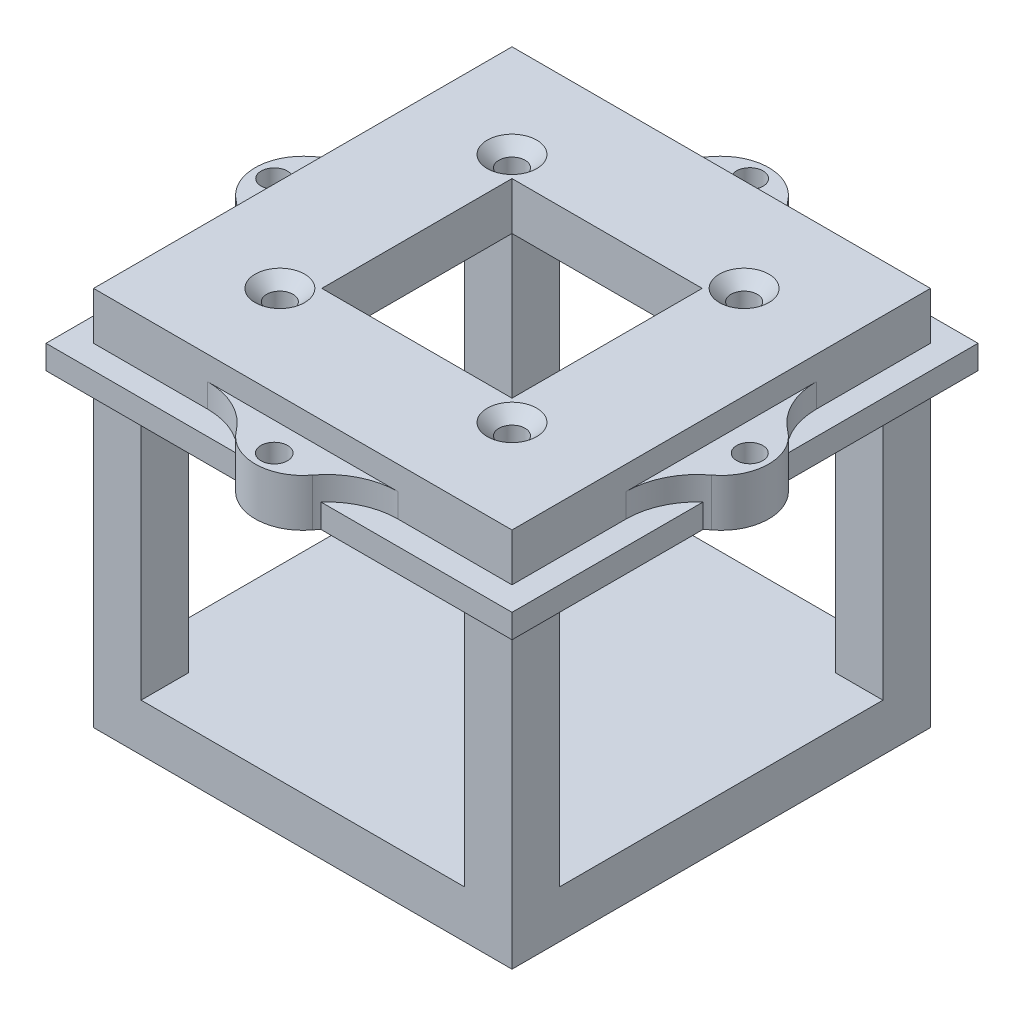
from build123d import *

# Parameters (mm, degrees)
SKETCH1_W                = 55.88
SKETCH1_H                = 55.88
BOSS_EXTRUDE1_DEPTH      = 50.8
SKETCH2_W                = 43.18
SKETCH2_H                = 38.1
CUT_EXTRUDE1_DEPTH       = 56.88
SKETCH3_W                = 43.18
SKETCH3_H                = 38.1
CUT_EXTRUDE2_DEPTH       = 56.88
SKETCH4_R                = 1.75
SKETCH4_W                = 25.4
SKETCH4_H                = 25.4
CUT_EXTRUDE3_DEPTH       = 44.45
BOSS_EXTRUDE2_DEPTH      = 3.175
BOSS_EXTRUDE2_DEPTH_BACK = 3.175
SKETCH10_W               = 9.525
SKETCH10_H               = 3.175
BOSS_EXTRUDE5_DEPTH      = 55.88
SKETCH12_W               = 62.23
SKETCH12_H               = 3.175
BOSS_EXTRUDE6_DEPTH      = 3.175
BOSS_EXTRUDE6_DEPTH_BACK = 6.35
SKETCH13_W               = 62.23
SKETCH13_H               = 3.175
BOSS_EXTRUDE7_DEPTH      = 3.175
BOSS_EXTRUDE7_DEPTH_BACK = 6.35
SKETCH11_R               = 1.75
SKETCH11_R_2             = 1.778
CUT_EXTRUDE4_DEPTH       = 48.625
SKETCH15_R               = 2.54
SKETCH15_R_2             = 1.75
SKETCH15_R_3             = 1.778
BOSS_EXTRUDE8_DEPTH      = 7.239
SKETCH16_R               = 1.651
BOSS_EXTRUDE9_DEPTH      = 3.175


with BuildPart() as part:
    # Sketch1 → Boss-Extrude1 (new body)
    with BuildSketch(Plane(origin=(0, 0, 0), x_dir=(1, 0, 0), z_dir=(0, 1, 0))):
        with Locations((27.94, 27.94)):
            Rectangle(SKETCH1_W, SKETCH1_H)
    extrude(amount=BOSS_EXTRUDE1_DEPTH)

    # Sketch2 → Cut-Extrude1 (cut, through all)
    with BuildSketch(Plane.XY):
        with Locations((27.94, 25.4)):
            Rectangle(SKETCH2_W, SKETCH2_H)
    extrude(amount=-CUT_EXTRUDE1_DEPTH, mode=Mode.SUBTRACT)

    # Sketch3 → Cut-Extrude2 (cut, through all)
    with BuildSketch(Plane(origin=(55.88, 0, 0), x_dir=(0, 0, -1), z_dir=(1, 0, 0))):
        with Locations((27.94, 25.4)):
            Rectangle(SKETCH3_W, SKETCH3_H)
    extrude(amount=-CUT_EXTRUDE2_DEPTH, mode=Mode.SUBTRACT)

    # Sketch4 → Cut-Extrude3 (cut)
    with BuildSketch(Plane(origin=(0, 50.8, 0), x_dir=(1, 0, 0), z_dir=(0, 1, 0))):
        with Locations((43.44, 43.44)):
            Circle(SKETCH4_R)
        with Locations((43.44, 12.44)):
            Circle(SKETCH4_R)
        with Locations((12.44, 12.44)):
            Circle(SKETCH4_R)
        with Locations((12.44, 43.44)):
            Circle(SKETCH4_R)
        with Locations((27.94, 27.94)):
            Rectangle(SKETCH4_W, SKETCH4_H)
    extrude(amount=-CUT_EXTRUDE3_DEPTH, mode=Mode.SUBTRACT)

    # Sketch5 → Cut-Revolve1 (revolve, cut)
    with BuildSketch(Plane(origin=(12.44, 0, 0), x_dir=(0, 0, -1), z_dir=(1, 0, 0))):
        Polygon((43.44, 50.8), (40.138, 50.8), (43.44, 47.498), align=None)
    revolve(axis=Axis((12.44, 47.498, -43.44), (0, 1, 0)), mode=Mode.SUBTRACT)

    # Sketch6 → Cut-Revolve2 (revolve, cut)
    with BuildSketch(Plane(origin=(12.44, 0, 0), x_dir=(0, 0, -1), z_dir=(1, 0, 0))):
        Polygon((12.44, 50.8), (9.138, 50.8), (12.44, 47.498), align=None)
    revolve(axis=Axis((12.44, 47.498, -12.44), (0, 1, 0)), mode=Mode.SUBTRACT)

    # Sketch7 → Cut-Revolve3 (revolve, cut)
    with BuildSketch(Plane(origin=(43.44, 0, 0), x_dir=(0, 0, -1), z_dir=(1, 0, 0))):
        Polygon((43.44, 50.8), (40.138, 50.8), (43.44, 47.498), align=None)
    revolve(axis=Axis((43.44, 47.498, -43.44), (0, 1, 0)), mode=Mode.SUBTRACT)

    # Sketch8 → Cut-Revolve4 (revolve, cut)
    with BuildSketch(Plane(origin=(43.44, 0, 0), x_dir=(0, 0, -1), z_dir=(1, 0, 0))):
        Polygon((12.44, 50.8), (9.138, 50.8), (12.44, 47.498), align=None)
    revolve(axis=Axis((43.44, 47.498, -12.44), (0, 1, 0)), mode=Mode.SUBTRACT)

    # Sketch9 → Boss-Extrude2 (add, two sides)
    with BuildSketch(Plane.XZ.offset(-44.45)) as boss_extrude2_sk:
        with BuildLine():
            Line((0, -40.64), (0, -15.24))
            ThreePointArc((0, -15.24), (-1.005581006, -19.499709497), (-3.81, -22.86))
            ThreePointArc((-3.81, -22.86), (-6.35, -27.94), (-3.81, -33.02))
            ThreePointArc((-3.81, -33.02), (-1.005581006, -36.380290503), (0, -40.64))
        make_face()
        with BuildLine():
            Line((55.88, -40.64), (55.88, -15.24))
            ThreePointArc((55.88, -15.24), (56.885581006, -19.499709497), (59.69, -22.86))
            ThreePointArc((59.69, -22.86), (62.23, -27.94), (59.69, -33.02))
            ThreePointArc((59.69, -33.02), (56.885581006, -36.380290503), (55.88, -40.64))
        make_face()
        with BuildLine():
            Line((15.24, 0), (40.64, 0))
            ThreePointArc((40.64, 0), (36.380290503, 1.005581006), (33.02, 3.81))
            ThreePointArc((33.02, 3.81), (27.94, 6.35), (22.86, 3.81))
            ThreePointArc((22.86, 3.81), (19.499709497, 1.005581006), (15.24, 0))
        make_face()
        with BuildLine():
            Line((15.24, -55.88), (40.64, -55.88))
            ThreePointArc((40.64, -55.88), (36.380290503, -56.885581006), (33.02, -59.69))
            ThreePointArc((33.02, -59.69), (27.94, -62.23), (22.86, -59.69))
            ThreePointArc((22.86, -59.69), (19.499709497, -56.885581006), (15.24, -55.88))
        make_face()
    extrude(amount=BOSS_EXTRUDE2_DEPTH)
    extrude(boss_extrude2_sk.sketch, amount=-BOSS_EXTRUDE2_DEPTH_BACK)

    # Sketch10 → Boss-Extrude5 (add)
    with BuildSketch(Plane.XY):
        with Locations((54.2925, 42.8625)):
            Rectangle(SKETCH10_W, SKETCH10_H)
        with Locations((1.5875, 42.8625)):
            Rectangle(SKETCH10_W, SKETCH10_H)
    extrude(amount=-BOSS_EXTRUDE5_DEPTH)

    # Sketch12 → Boss-Extrude6 (add, two sides)
    with BuildSketch(Plane(origin=(0, 0, -55.88), x_dir=(-1, 0, 0), z_dir=(0, 0, -1))) as boss_extrude6_sk:
        with Locations((-27.94, 42.8625)):
            Rectangle(SKETCH12_W, SKETCH12_H)
    extrude(amount=BOSS_EXTRUDE6_DEPTH)
    extrude(boss_extrude6_sk.sketch, amount=-BOSS_EXTRUDE6_DEPTH_BACK)

    # Sketch13 → Boss-Extrude7 (add, two sides)
    with BuildSketch(Plane.XY) as boss_extrude7_sk:
        with Locations((27.94, 42.8625)):
            Rectangle(SKETCH13_W, SKETCH13_H)
    extrude(amount=BOSS_EXTRUDE7_DEPTH)
    extrude(boss_extrude7_sk.sketch, amount=-BOSS_EXTRUDE7_DEPTH_BACK)

    # Sketch11 → Cut-Extrude4 (cut, through all)
    with BuildSketch(Plane(origin=(0, 47.625, 0), x_dir=(1, 0, 0), z_dir=(0, 1, 0))):
        with Locations((-3.81, 27.94)):
            Circle(SKETCH11_R)
        with Locations((59.69, 27.94)):
            Circle(SKETCH11_R)
        with Locations((27.94, -3.81)):
            Circle(SKETCH11_R_2)
        with Locations((27.94, 59.69)):
            Circle(SKETCH11_R_2)
    extrude(amount=-CUT_EXTRUDE4_DEPTH, mode=Mode.SUBTRACT)

    # Sketch14 → Revolve1 (revolve)
    with BuildSketch(Plane(origin=(0, 0, -27.94), x_dir=(-1, 0, 0), z_dir=(0, 0, -1))):
        with BuildLine():
            Line((-8.89, 0), (-24.765, -2.888501777))
            ThreePointArc((-24.765, -2.888501777), (-26.346050014, -3.103230235), (-27.94, -3.175))
            Line((-27.94, -3.175), (-27.94, 0))
            Line((-27.94, 0), (-8.89, 0))
        make_face()
    revolve(axis=Axis((27.94, -3.175, -27.94), (0, 1, 0)))

    # Sketch15 → Boss-Extrude8 (add)
    with BuildSketch(Plane.XZ.offset(-41.275)):
        with Locations((-3.81, -27.94)):
            Circle(SKETCH15_R)
        with Locations((-3.81, -27.94)):
            Circle(SKETCH15_R_2, mode=Mode.SUBTRACT)
        with Locations((27.94, -59.69)):
            Circle(SKETCH15_R)
        with Locations((27.94, -59.69)):
            Circle(SKETCH15_R_3, mode=Mode.SUBTRACT)
    extrude(amount=BOSS_EXTRUDE8_DEPTH)

    # Sketch16 → Boss-Extrude9 (add)
    with BuildSketch(Plane.XZ.offset(-34.036)):
        with BuildLine():
            Line((34.29, -62.23), (21.59, -62.23))
            ThreePointArc((21.59, -62.23), (19.05, -59.69), (21.59, -57.15))
            Line((21.59, -57.15), (34.29, -57.15))
            ThreePointArc((34.29, -57.15), (36.83, -59.69), (34.29, -62.23))
        make_face()
        with Locations((34.29, -59.69)):
            Circle(SKETCH16_R, mode=Mode.SUBTRACT)
        with Locations((21.59, -59.69)):
            Circle(SKETCH16_R, mode=Mode.SUBTRACT)
        with BuildLine():
            Line((-6.35, -34.29), (-6.35, -21.59))
            ThreePointArc((-6.35, -21.59), (-3.81, -19.05), (-1.27, -21.59))
            Line((-1.27, -21.59), (-1.27, -34.29))
            ThreePointArc((-1.27, -34.29), (-3.81, -36.83), (-6.35, -34.29))
        make_face()
        with Locations((-3.81, -34.29)):
            Circle(SKETCH16_R, mode=Mode.SUBTRACT)
        with Locations((-3.81, -21.59)):
            Circle(SKETCH16_R, mode=Mode.SUBTRACT)
    extrude(amount=BOSS_EXTRUDE9_DEPTH)


solid = part.part
